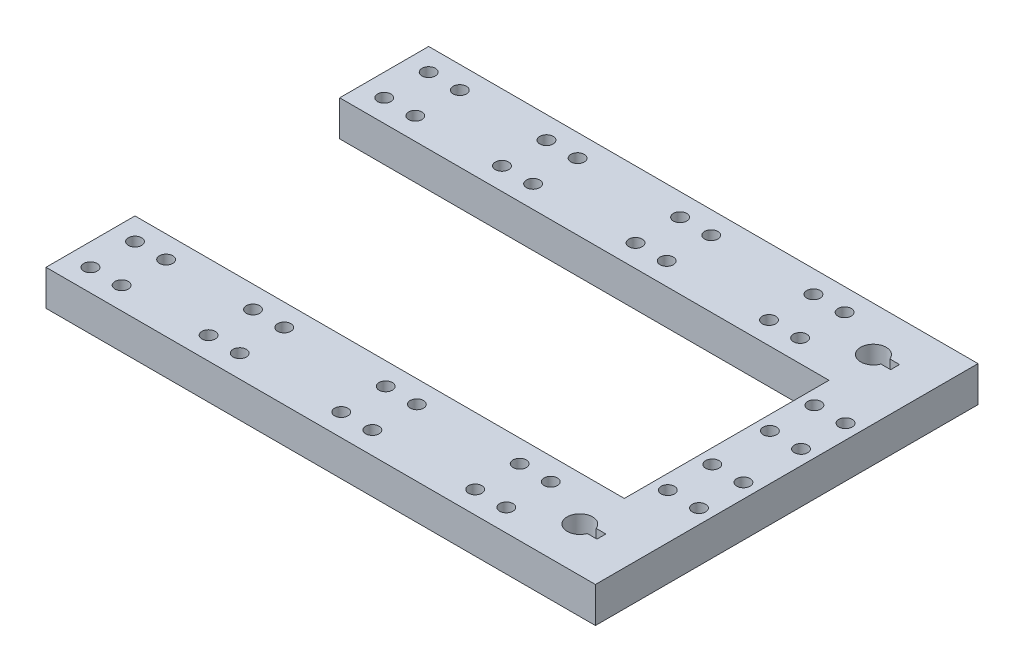
from build123d import *

# Parameters (mm, degrees)
SKETCH1_R           = 1.5
BOSS_EXTRUDE3_DEPTH = 8


with BuildPart() as part:
    # Sketch1 → Boss-Extrude3 (new body)
    with BuildSketch(Plane(origin=(0, 0, 0), x_dir=(1, 0, 0), z_dir=(0, 1, 0))):
        Polygon((21, 42.996794864), (21, 22.996794864), (130.982222222, 22.996794864), (130.982222222, -23.003205136), (20.982222222, -23.003205136), (20.982222222, -43.003205136), (144.482222222, -43.003205136), (144.482222222, -40.503205136), (144.482222222, 42.996794864), align=None)
        with BuildLine():
            ThreePointArc((133.652222222, -34), (128.132224278, -33.006627887), (133.649820291, -32))
            Line((133.649820291, -32), (135.832222222, -32))
            Line((135.832222222, -32), (135.832222222, -34))
            Line((135.832222222, -34), (133.652222222, -34))
        make_face(mode=Mode.SUBTRACT)
        with BuildLine():
            ThreePointArc((27.482222222, -38.003205136), (24.92156205, -39.063865308), (25.982222222, -36.503205136))
            ThreePointArc((25.982222222, -36.503205136), (27.042882394, -36.942544965), (27.482222222, -38.003205136))
        make_face(mode=Mode.SUBTRACT)
        with Locations((32.982222222, -38.003205136)):
            Circle(SKETCH1_R, mode=Mode.SUBTRACT)
        with Locations((52.475249167, -37.951512162)):
            Circle(SKETCH1_R, mode=Mode.SUBTRACT)
        with Locations((59.475249167, -37.951512162)):
            Circle(SKETCH1_R, mode=Mode.SUBTRACT)
        with Locations((82.343483879, -38.002656399)):
            Circle(SKETCH1_R, mode=Mode.SUBTRACT)
        with Locations((89.343483879, -38.002656399)):
            Circle(SKETCH1_R, mode=Mode.SUBTRACT)
        with Locations((112.464813863, -38.013925916)):
            Circle(SKETCH1_R, mode=Mode.SUBTRACT)
        with Locations((119.464813863, -38.013925916)):
            Circle(SKETCH1_R, mode=Mode.SUBTRACT)
        with Locations((134.24655623, -16.49373389)):
            Circle(SKETCH1_R, mode=Mode.SUBTRACT)
        with Locations((141.24655623, -16.49373389)):
            Circle(SKETCH1_R, mode=Mode.SUBTRACT)
        with Locations((134.24655623, -6.49373389)):
            Circle(SKETCH1_R, mode=Mode.SUBTRACT)
        with Locations((141.24655623, -6.49373389)):
            Circle(SKETCH1_R, mode=Mode.SUBTRACT)
        with BuildLine():
            ThreePointArc((27.5, 27.996794864), (24.939339828, 26.936134692), (26, 29.496794864))
            ThreePointArc((26, 29.496794864), (27.060660172, 29.057455035), (27.5, 27.996794864))
        make_face(mode=Mode.SUBTRACT)
        with Locations((33, 27.996794864)):
            Circle(SKETCH1_R, mode=Mode.SUBTRACT)
        with Locations((52.486589883, 27.989732879)):
            Circle(SKETCH1_R, mode=Mode.SUBTRACT)
        with Locations((26, 37.996794864)):
            Circle(SKETCH1_R, mode=Mode.SUBTRACT)
        with Locations((33, 37.996794864)):
            Circle(SKETCH1_R, mode=Mode.SUBTRACT)
        with Locations((52.486589883, 37.989732879)):
            Circle(SKETCH1_R, mode=Mode.SUBTRACT)
        with Locations((59.486589883, 27.989732879)):
            Circle(SKETCH1_R, mode=Mode.SUBTRACT)
        with Locations((82.502017716, 27.999509045)):
            Circle(SKETCH1_R, mode=Mode.SUBTRACT)
        with Locations((59.486589883, 37.989732879)):
            Circle(SKETCH1_R, mode=Mode.SUBTRACT)
        with Locations((82.502017716, 37.999509045)):
            Circle(SKETCH1_R, mode=Mode.SUBTRACT)
        with Locations((134.199672827, 6.49839835)):
            Circle(SKETCH1_R, mode=Mode.SUBTRACT)
        with Locations((141.199672827, 6.49839835)):
            Circle(SKETCH1_R, mode=Mode.SUBTRACT)
        with Locations((134.199672827, 16.49839835)):
            Circle(SKETCH1_R, mode=Mode.SUBTRACT)
        with Locations((141.199672827, 16.49839835)):
            Circle(SKETCH1_R, mode=Mode.SUBTRACT)
        with Locations((89.502017716, 27.999509045)):
            Circle(SKETCH1_R, mode=Mode.SUBTRACT)
        with Locations((112.502146229, 27.991574488)):
            Circle(SKETCH1_R, mode=Mode.SUBTRACT)
        with Locations((89.502017716, 37.999509045)):
            Circle(SKETCH1_R, mode=Mode.SUBTRACT)
        with Locations((112.502146229, 37.991574488)):
            Circle(SKETCH1_R, mode=Mode.SUBTRACT)
        with Locations((119.502146229, 27.991574488)):
            Circle(SKETCH1_R, mode=Mode.SUBTRACT)
        with Locations((119.502146229, 37.991574488)):
            Circle(SKETCH1_R, mode=Mode.SUBTRACT)
        with BuildLine():
            Line((133.67, 33.996794864), (135.85, 33.996794864))
            Line((135.85, 33.996794864), (135.85, 31.996794864))
            Line((135.85, 31.996794864), (133.67, 31.996794864))
            ThreePointArc((133.67, 31.996794864), (128.114444444, 32.996794864), (133.67, 33.996794864))
        make_face(mode=Mode.SUBTRACT)
        with Locations((89.343483879, -28.002656399)):
            Circle(SKETCH1_R, mode=Mode.SUBTRACT)
        with Locations((112.464813863, -28.013925916)):
            Circle(SKETCH1_R, mode=Mode.SUBTRACT)
        with Locations((119.464813863, -28.013925916)):
            Circle(SKETCH1_R, mode=Mode.SUBTRACT)
        with Locations((52.475249167, -27.951512162)):
            Circle(SKETCH1_R, mode=Mode.SUBTRACT)
        with Locations((59.475249167, -27.951512162)):
            Circle(SKETCH1_R, mode=Mode.SUBTRACT)
        with Locations((25.982222222, -28.003205136)):
            Circle(SKETCH1_R, mode=Mode.SUBTRACT)
        with Locations((32.982222222, -28.003205136)):
            Circle(SKETCH1_R, mode=Mode.SUBTRACT)
        with Locations((82.343483879, -28.002656399)):
            Circle(SKETCH1_R, mode=Mode.SUBTRACT)
    extrude(amount=BOSS_EXTRUDE3_DEPTH)


solid = part.part
